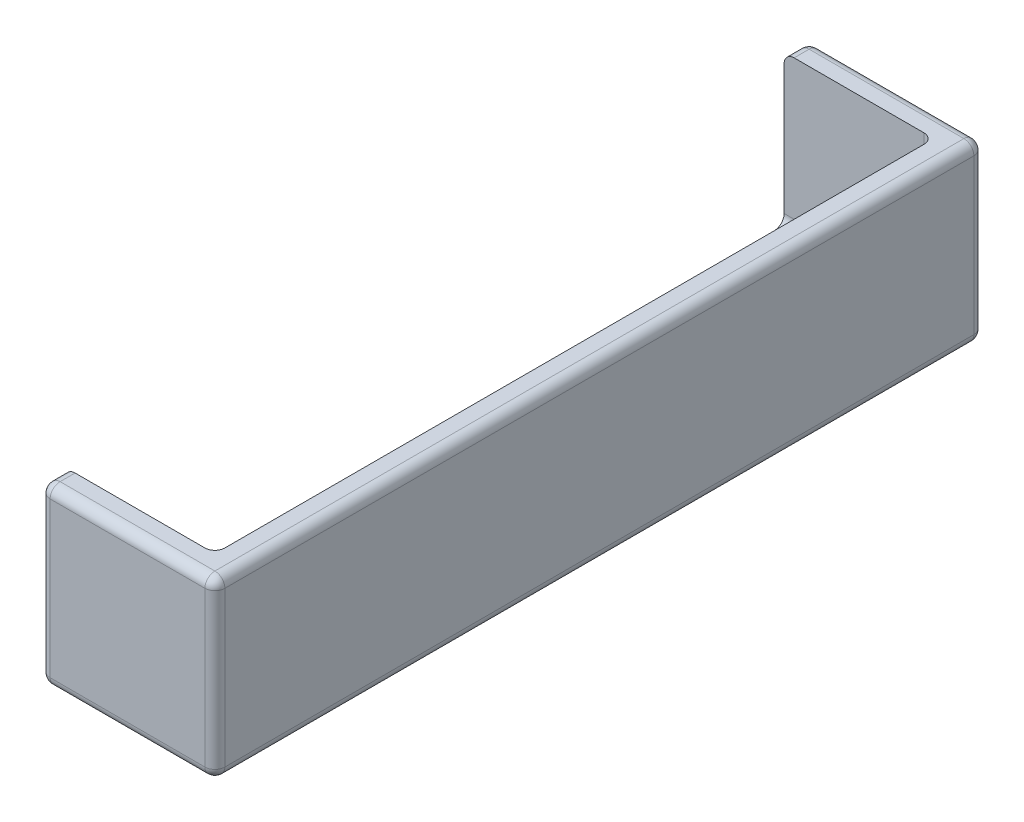
from build123d import *

# Parameters (mm, degrees)
ESQUISSE1_W             = 17.5
ESQUISSE1_H             = 17.5
BOSS_EXTRU_1_DEPTH      = 77
ESQUISSE2_W             = 72
ESQUISSE2_H             = 20
ENL_V_MAT_EXTRU_1_DEPTH = 15
CONG_1_R                = 1


with BuildPart() as part:
    # Esquisse1 → Boss.-Extru.1 (new body)
    with BuildSketch(Plane.XY):
        with Locations((8.75, 8.75)):
            Rectangle(ESQUISSE1_W, ESQUISSE1_H)
    extrude(amount=BOSS_EXTRU_1_DEPTH)

    # Esquisse2 → Enlèv. mat.-Extru.1 (cut)
    with BuildSketch(Plane.ZY):
        with Locations((38.5, 12.5)):
            Rectangle(ESQUISSE2_W, ESQUISSE2_H)
    extrude(amount=-ENL_V_MAT_EXTRU_1_DEPTH, mode=Mode.SUBTRACT)

    # Congé1
    cong_1_edges = [part.edges().sort_by_distance(p)[0] for p in [
        (8.75, 17.5, 77),
        (0, 17.5, 1.25),
        (17.5, 8.75, 77),
        (15, 10, 2.5),
        (7.5, 2.5, 2.5),
        (15, 10, 74.5),
        (15, 2.5, 38.5),
        (7.5, 2.5, 74.5),
        (8.75, 0, 77),
        (17.5, 8.75, 0),
        (8.75, 17.5, 0),
        (0, 8.75, 0),
        (8.75, 0, 0),
        (17.5, 0, 38.5),
        (17.5, 17.5, 38.5),
        (0, 17.5, 75.75),
        (0, 0, 38.5),
        (0, 8.75, 77),
    ]]
    fillet(cong_1_edges, radius=CONG_1_R)


solid = part.part
